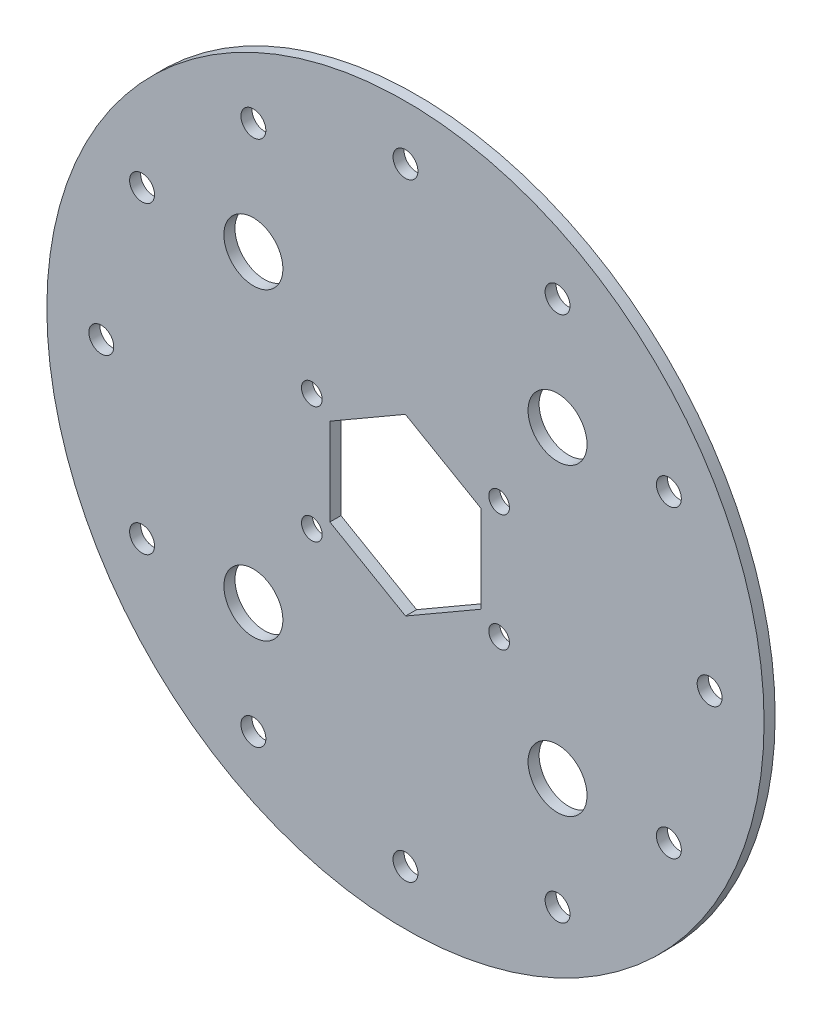
from build123d import *

# Parameters (mm, degrees)
SKETCH1_R               = 97.28
SKETCH1_R_2             = 2.8067
SKETCH1_R_3             = 8
BOSS_EXTRUDE1_DEPTH     = 3
F_1_4_CLEARANCE_HOLE1_D = 6.7564


with BuildPart() as part:
    # Sketch1 → Boss-Extrude1 (new body)
    with BuildSketch(Plane.XY):
        with Locations((36.235962131, -23.183312097)):
            Circle(SKETCH1_R)
        with Locations((61.635962131, -7.308312097)):
            Circle(SKETCH1_R_2, mode=Mode.SUBTRACT)
        with Locations((61.635962131, -39.058312097)):
            Circle(SKETCH1_R_2, mode=Mode.SUBTRACT)
        with Locations((10.835962131, -39.058312097)):
            Circle(SKETCH1_R_2, mode=Mode.SUBTRACT)
        with Locations((10.835962131, -7.308312097)):
            Circle(SKETCH1_R_2, mode=Mode.SUBTRACT)
        with Locations((-5.014037869, -64.433312097)):
            Circle(SKETCH1_R_3, mode=Mode.SUBTRACT)
        with Locations((77.485962131, -64.433312097)):
            Circle(SKETCH1_R_3, mode=Mode.SUBTRACT)
        with Locations((77.485962131, 18.066687903)):
            Circle(SKETCH1_R_3, mode=Mode.SUBTRACT)
        with Locations((-5.014037869, 18.066687903)):
            Circle(SKETCH1_R_3, mode=Mode.SUBTRACT)
        Polygon((15.735962131, -35.032829738), (36.247945431, -46.861591696), (56.747945431, -35.012074055), (56.735962131, -11.333794456), (36.223978831, 0.494967501), (15.723978831, -11.35455014), align=None, mode=Mode.SUBTRACT)
    extrude(amount=BOSS_EXTRUDE1_DEPTH)

    # 1/4 Clearance Hole1 (through all)
    with Locations(Plane(origin=(0, 0, 0), x_dir=(-1, 0, 0), z_dir=(0, 0, -1))):
        with Locations((-118.735962131, -23.183312097), (-107.683057943, -64.433312097), (46.264037869, -23.183312097), (35.211133681, -64.433312097), (-77.485962131, -94.63040791), (-36.235962131, -105.683312097), (5.014037869, -94.63040791), (35.211133681, 18.066687903), (5.014037869, 48.263783715), (-36.235962131, 59.316687903), (-77.485962131, 48.263783715), (-107.683057943, 18.066687903)):
            Hole(F_1_4_CLEARANCE_HOLE1_D / 2)


solid = part.part
